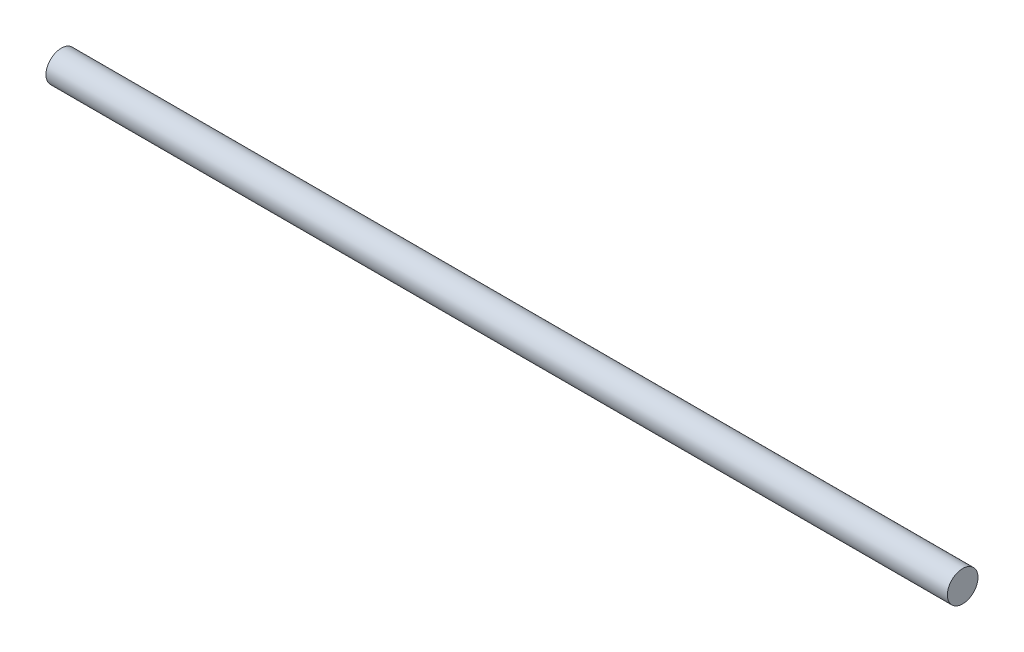
from build123d import *

# Parameters (mm, degrees)
CROQUIS1_R              = 0.85
SALIENTE_EXTRUIR1_DEPTH = 25


with BuildPart() as part:
    # Croquis1 → Saliente-Extruir1 (new body, symmetric)
    with BuildSketch(Plane(origin=(0, 0, 0), x_dir=(0, 0, -1), z_dir=(1, 0, 0))):
        Circle(CROQUIS1_R)
    extrude(amount=SALIENTE_EXTRUIR1_DEPTH, both=True)


solid = part.part
